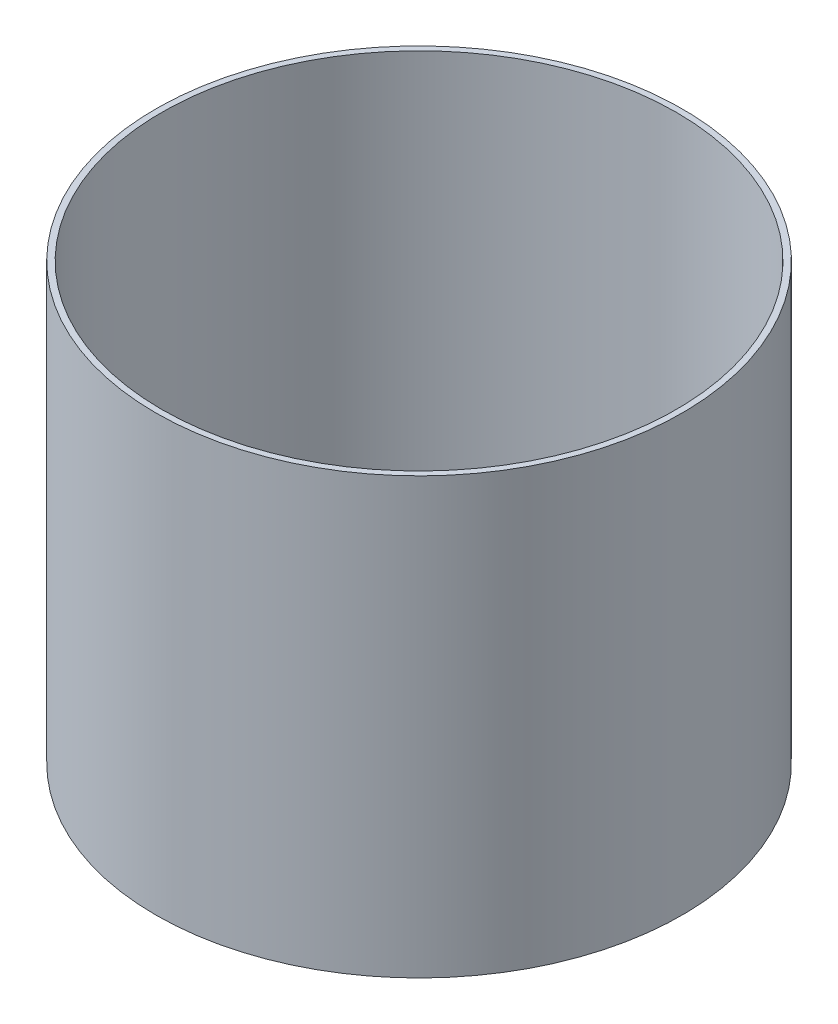
from build123d import *

# Parameters (mm, degrees)
SKETCH_1_R      = 22.1
SKETCH_1_R_2    = 21.6
EXTRUDE_1_DEPTH = 36.5


with BuildPart() as part:
    # 草图1 → 凸台-拉伸1 (new body)
    with BuildSketch(Plane(origin=(0, 0, 0), x_dir=(1, 0, 0), z_dir=(0, 1, 0))):
        Circle(SKETCH_1_R)
        Circle(SKETCH_1_R_2, mode=Mode.SUBTRACT)
    extrude(amount=EXTRUDE_1_DEPTH)


solid = part.part
